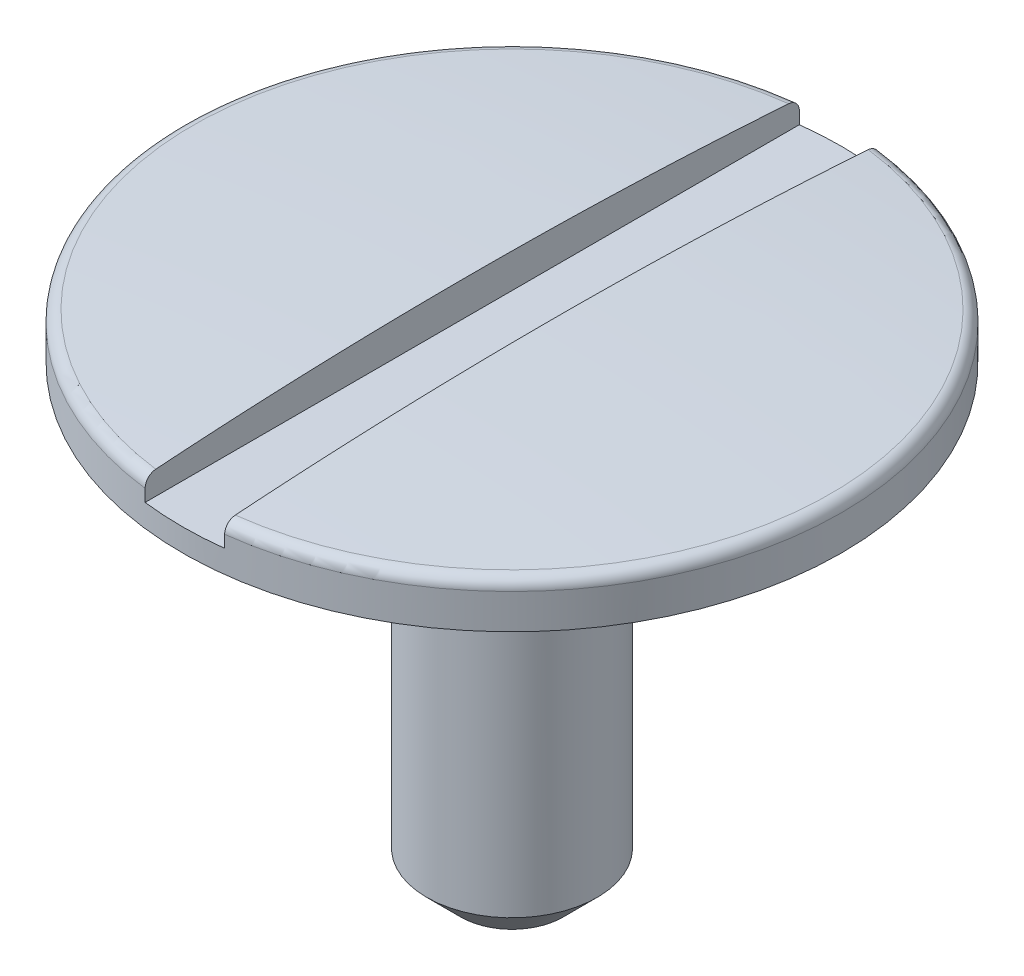
from build123d import *

# Parameters (mm, degrees)
SKETCH2_R               = 0.375
BOSS_EXTRUDE2_DEPTH     = 2
FILLET1_R               = 0.05
CHAMFER2_SIZE           = 0.15
CUT_EXTRUDE1_DEPTH      = 2.4500001
CUT_EXTRUDE1_DEPTH_BACK = 2.4500001


with BuildPart() as part:
    # Sketch4 → Revolve1 (revolve)
    with BuildSketch(Plane.XY):
        with BuildLine():
            Line((0, 0), (1.45, 0))
            Line((1.45, 0), (1.45, 0.2))
            ThreePointArc((1.45, 0.2), (0.725477446, 0.239469483), (0, 0.252631753))
            Line((0, 0.252631753), (0, 0))
        make_face()
    revolve(axis=Axis((0, -848.356227188, 0), (0, 1, 0)))

    # Sketch2 → Boss-Extrude2 (add)
    with BuildSketch(Plane(origin=(0, 0, 0), x_dir=(1, 0, 0), z_dir=(0, 1, 0))):
        Circle(SKETCH2_R)
    extrude(amount=-BOSS_EXTRUDE2_DEPTH)

    # Fillet1
    fillet1_edges = [part.edges().sort_by_distance(p)[0] for p in [
        (-1.45, 0.2, 0),
    ]]
    fillet(fillet1_edges, radius=FILLET1_R)

    # Chamfer2
    chamfer2_edges = [part.edges().sort_by_distance(p)[0] for p in [
        (-0.375, -2, 0),
    ]]
    chamfer(chamfer2_edges, length=CHAMFER2_SIZE)

    # Sketch3 → Cut-Extrude1 (cut, two sides)
    with BuildSketch(Plane.XY) as cut_extrude1_sk:
        Polygon((-0.175, 0.35), (0, 0.35), (0.175, 0.35), (0.175, 0.1), (0, 0.1), (-0.175, 0.1), align=None)
    extrude(amount=CUT_EXTRUDE1_DEPTH, mode=Mode.SUBTRACT)
    extrude(cut_extrude1_sk.sketch, amount=-CUT_EXTRUDE1_DEPTH_BACK, mode=Mode.SUBTRACT)


solid = part.part
